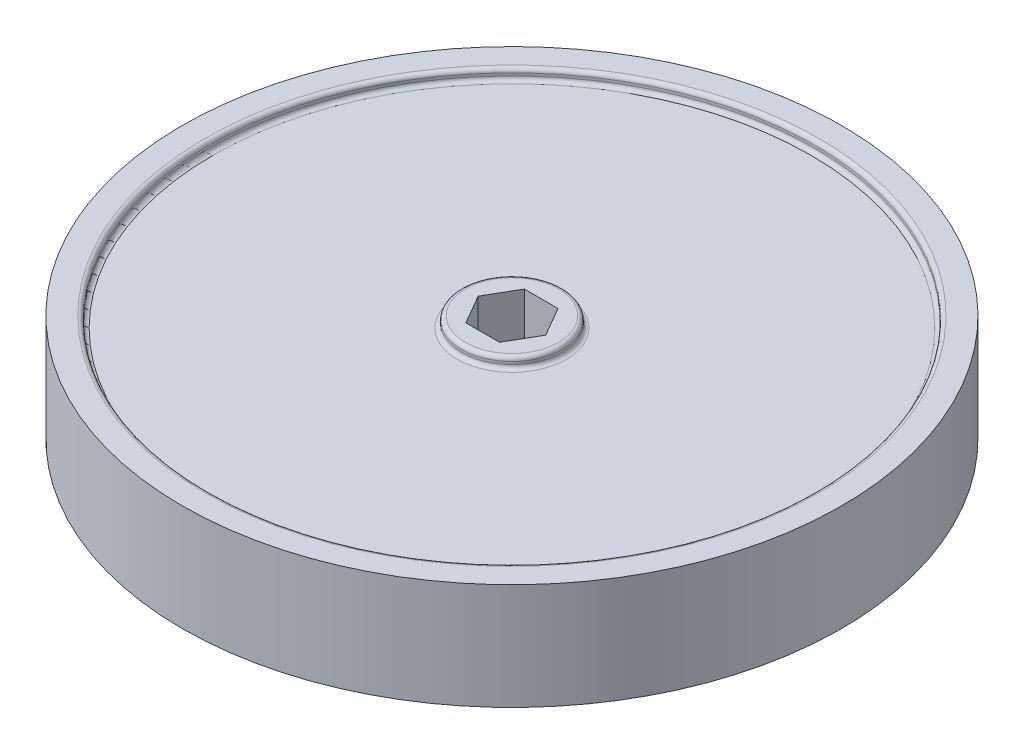
from build123d import *

# Parameters (mm, degrees)
SCHIZZO1_W                    = 62
SCHIZZO1_H                    = 20
SCHIZZO9_R                    = 57
TAGLIO_ESTRUSIONE2_DEPTH      = 2
SCHIZZO10_R                   = 9.5
ESTRUSIONE_ESTRUSIONE3_DEPTH  = 2
TAGLIO_ESTRUSIONE1_DEPTH      = 19
TAGLIO_ESTRUSIONE1_DEPTH_BACK = 3
RACCORDO1_R                   = 0.75


with BuildPart() as part:
    # Schizzo1 → Rivoluzione1 (revolve)
    with BuildSketch(Plane(origin=(0, 0, 0), x_dir=(-1, 0, 0), z_dir=(0, 0, -1))):
        with Locations((-31, 0)):
            Rectangle(SCHIZZO1_W, SCHIZZO1_H)
    revolve(axis=Axis((0, -10, 0), (0, 1, 0)))

    # Schizzo9 → Taglio-Estrusione2 (cut)
    with BuildSketch(Plane.XZ.offset(10)):
        Circle(SCHIZZO9_R)
    taglio_estrusione2 = extrude(amount=-TAGLIO_ESTRUSIONE2_DEPTH, mode=Mode.SUBTRACT)

    # Schizzo10 → Estrusione-Estrusione3 (add)
    with BuildSketch(Plane.XZ.offset(8)):
        Circle(SCHIZZO10_R)
    estrusione_estrusione3 = extrude(amount=ESTRUSIONE_ESTRUSIONE3_DEPTH)

    # Specchia1: Taglio-Estrusione2, Estrusione-Estrusione3 across plane
    add(taglio_estrusione2.mirror(Plane.ZX), mode=Mode.SUBTRACT)
    add(estrusione_estrusione3.mirror(Plane.ZX))

    # Schizzo8 → Taglio-Estrusione1 (cut, two sides)
    with BuildSketch(Plane(origin=(0, -8, 0), x_dir=(-1, 0, 0), z_dir=(0, 1, 0))) as taglio_estrusione1_sk:
        Polygon((-3.175, -5.499261314), (3.175, -5.499261314), (6.35, 0), (3.175, 5.499261314), (-3.175, 5.499261314), (-6.35, 0), align=None)
    extrude(amount=TAGLIO_ESTRUSIONE1_DEPTH, mode=Mode.SUBTRACT)
    extrude(taglio_estrusione1_sk.sketch, amount=-TAGLIO_ESTRUSIONE1_DEPTH_BACK, mode=Mode.SUBTRACT)

    # Raccordo1
    raccordo1_edges = [part.edges().sort_by_distance(p)[0] for p in [
        (-57, -10, 0),
        (-9.5, -10, 0),
        (-57, 10, 0),
        (-57, 8, 0),
        (-9.5, 8, 0),
        (-9.5, 10, 0),
        (-57, -8, 0),
    ]]
    fillet(raccordo1_edges, radius=RACCORDO1_R)


solid = part.part
